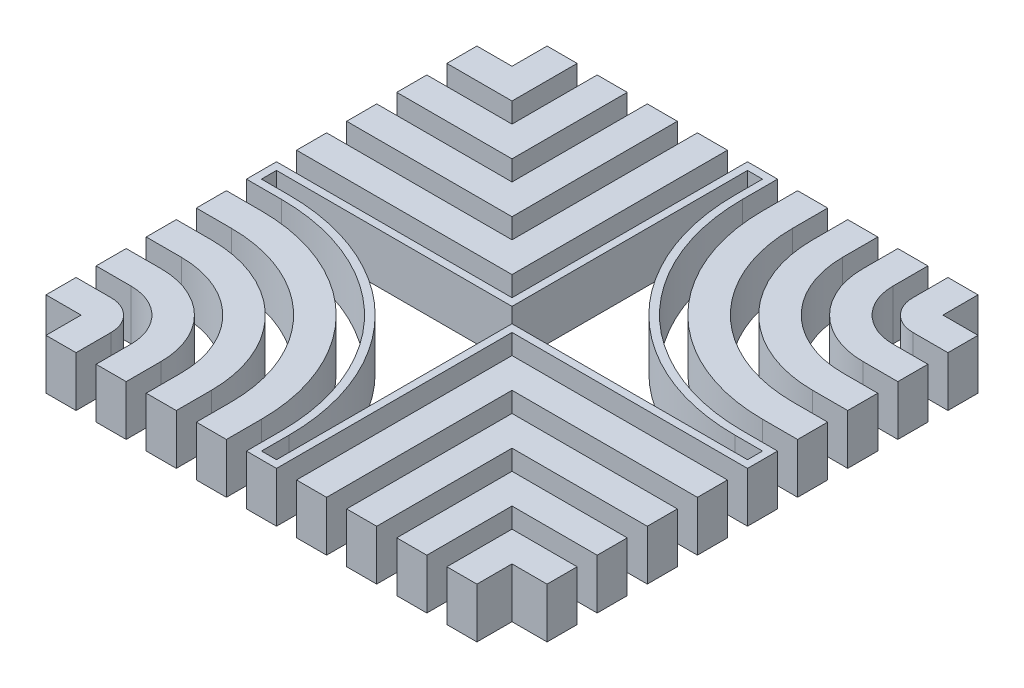
from build123d import *

# Parameters (mm, degrees)
BOSS_EXTRUDE1_DEPTH    = 10
BOSS_EXTRUDE1_2_DEPTH  = 10
BOSS_EXTRUDE1_3_DEPTH  = 10
BOSS_EXTRUDE1_4_DEPTH  = 10
BOSS_EXTRUDE1_5_DEPTH  = 10
BOSS_EXTRUDE1_6_DEPTH  = 10
BOSS_EXTRUDE1_7_DEPTH  = 10
BOSS_EXTRUDE1_8_DEPTH  = 10
BOSS_EXTRUDE1_9_DEPTH  = 10
BOSS_EXTRUDE1_10_DEPTH = 10
BOSS_EXTRUDE1_11_DEPTH = 10
BOSS_EXTRUDE1_12_DEPTH = 10
BOSS_EXTRUDE1_13_DEPTH = 10
BOSS_EXTRUDE1_14_DEPTH = 10
BOSS_EXTRUDE1_15_DEPTH = 10
BOSS_EXTRUDE1_16_DEPTH = 10
BOSS_EXTRUDE1_17_DEPTH = 10
SHELL1_T               = -1.5


with BuildPart() as part:
    # Sketch1 → Boss-Extrude1 (new body)
    with BuildSketch(Plane(origin=(0, 0, 0), x_dir=(1, 0, 0), z_dir=(0, 1, 0))):
        Polygon((-50, 37), (-37, 37), (-37, 50), (-43, 50), (-43, 43), (-50, 43), align=None)
    extrude(amount=BOSS_EXTRUDE1_DEPTH)


with BuildPart() as body_2:
    # Sketch1 → Boss-Extrude1 2 (new body)
    with BuildSketch(Plane(origin=(0, 0, 0), x_dir=(1, 0, 0), z_dir=(0, 1, 0))):
        Polygon((-50, 27), (-27, 27), (-27, 50), (-33, 50), (-33, 33), (-50, 33), align=None)
    extrude(amount=BOSS_EXTRUDE1_2_DEPTH)


with BuildPart() as body_3:
    # Sketch1 → Boss-Extrude1 3 (new body)
    with BuildSketch(Plane(origin=(0, 0, 0), x_dir=(1, 0, 0), z_dir=(0, 1, 0))):
        Polygon((-50, 17), (-17, 17), (-17, 50), (-23, 50), (-23, 23), (-50, 23), align=None)
    extrude(amount=BOSS_EXTRUDE1_3_DEPTH)


with BuildPart() as body_4:
    # Sketch1 → Boss-Extrude1 4 (new body)
    with BuildSketch(Plane(origin=(0, 0, 0), x_dir=(1, 0, 0), z_dir=(0, 1, 0))):
        Polygon((-50, 7), (-7, 7), (-7, 50), (-13, 50), (-13, 13), (-50, 13), align=None)
    extrude(amount=BOSS_EXTRUDE1_4_DEPTH)


with BuildPart() as body_5:
    # Sketch1 → Boss-Extrude1 5 (new body)
    with BuildSketch(Plane(origin=(0, 0, 0), x_dir=(1, 0, 0), z_dir=(0, 1, 0))):
        with BuildLine():
            Line((-50, -3), (-43, -3))
            ThreePointArc((-43, -3), (-14.715728753, -14.715728753), (-3, -43))
            Line((-3, -43), (-3, -50))
            Line((-3, -50), (3, -50))
            Line((3, -50), (3, -3))
            Line((3, -3), (50, -3))
            Line((50, -3), (50, 3))
            Line((50, 3), (43, 3))
            ThreePointArc((43, 3), (14.715728753, 14.715728753), (3, 43))
            Line((3, 43), (3, 50))
            Line((3, 50), (-3, 50))
            Line((-3, 50), (-3, 3))
            Line((-3, 3), (-50, 3))
            Line((-50, 3), (-50, -3))
        make_face()
    extrude(amount=BOSS_EXTRUDE1_5_DEPTH)

    # Shell1
    shell1_openings = [body_5.faces().sort_by_distance(p)[0] for p in [
        (0, 10, 0),
        (0, 0, 0),
    ]]
    offset(amount=SHELL1_T, openings=shell1_openings, kind=Kind.INTERSECTION)


with BuildPart() as body_6:
    # Sketch1 → Boss-Extrude1 6 (new body)
    with BuildSketch(Plane(origin=(0, 0, 0), x_dir=(1, 0, 0), z_dir=(0, 1, 0))):
        with BuildLine():
            Line((-50, -13), (-43, -13))
            ThreePointArc((-43, -13), (-21.786796564, -21.786796564), (-13, -43))
            Line((-13, -43), (-13, -50))
            Line((-13, -50), (-7, -50))
            Line((-7, -50), (-7, -43))
            ThreePointArc((-7, -43), (-17.544155877, -17.544155877), (-43, -7))
            Line((-43, -7), (-50, -7))
            Line((-50, -7), (-50, -13))
        make_face()
    extrude(amount=BOSS_EXTRUDE1_6_DEPTH)


with BuildPart() as body_7:
    # Sketch1 → Boss-Extrude1 7 (new body)
    with BuildSketch(Plane(origin=(0, 0, 0), x_dir=(1, 0, 0), z_dir=(0, 1, 0))):
        with BuildLine():
            Line((-50, -23), (-43, -23))
            ThreePointArc((-43, -23), (-28.857864376, -28.857864376), (-23, -43))
            Line((-23, -43), (-23, -50))
            Line((-23, -50), (-17, -50))
            Line((-17, -50), (-17, -43))
            ThreePointArc((-17, -43), (-24.615223689, -24.615223689), (-43, -17))
            Line((-43, -17), (-50, -17))
            Line((-50, -17), (-50, -23))
        make_face()
    extrude(amount=BOSS_EXTRUDE1_7_DEPTH)


with BuildPart() as body_8:
    # Sketch1 → Boss-Extrude1 8 (new body)
    with BuildSketch(Plane(origin=(0, 0, 0), x_dir=(1, 0, 0), z_dir=(0, 1, 0))):
        with BuildLine():
            Line((-50, -33), (-43, -33))
            ThreePointArc((-43, -33), (-35.928932188, -35.928932188), (-33, -43))
            Line((-33, -43), (-33, -50))
            Line((-33, -50), (-27, -50))
            Line((-27, -50), (-27, -43))
            ThreePointArc((-27, -43), (-31.686291501, -31.686291501), (-43, -27))
            Line((-43, -27), (-50, -27))
            Line((-50, -27), (-50, -33))
        make_face()
    extrude(amount=BOSS_EXTRUDE1_8_DEPTH)


with BuildPart() as body_9:
    # Sketch1 → Boss-Extrude1 9 (new body)
    with BuildSketch(Plane(origin=(0, 0, 0), x_dir=(1, 0, 0), z_dir=(0, 1, 0))):
        with BuildLine():
            Line((-50, -43), (-43, -43))
            Line((-43, -43), (-43, -50))
            Line((-43, -50), (-37, -50))
            Line((-37, -50), (-37, -43))
            ThreePointArc((-37, -43), (-38.757359313, -38.757359313), (-43, -37))
            Line((-43, -37), (-50, -37))
            Line((-50, -37), (-50, -43))
        make_face()
    extrude(amount=BOSS_EXTRUDE1_9_DEPTH)


with BuildPart() as body_10:
    # Sketch1 → Boss-Extrude1 10 (new body)
    with BuildSketch(Plane(origin=(0, 0, 0), x_dir=(1, 0, 0), z_dir=(0, 1, 0))):
        Polygon((7, -7), (50, -7), (50, -13), (13, -13), (13, -50), (7, -50), align=None)
    extrude(amount=BOSS_EXTRUDE1_10_DEPTH)


with BuildPart() as body_11:
    # Sketch1 → Boss-Extrude1 11 (new body)
    with BuildSketch(Plane(origin=(0, 0, 0), x_dir=(1, 0, 0), z_dir=(0, 1, 0))):
        Polygon((17, -17), (50, -17), (50, -23), (23, -23), (23, -50), (17, -50), align=None)
    extrude(amount=BOSS_EXTRUDE1_11_DEPTH)


with BuildPart() as body_12:
    # Sketch1 → Boss-Extrude1 12 (new body)
    with BuildSketch(Plane(origin=(0, 0, 0), x_dir=(1, 0, 0), z_dir=(0, 1, 0))):
        Polygon((27, -27), (50, -27), (50, -33), (33, -33), (33, -50), (27, -50), align=None)
    extrude(amount=BOSS_EXTRUDE1_12_DEPTH)


with BuildPart() as body_13:
    # Sketch1 → Boss-Extrude1 13 (new body)
    with BuildSketch(Plane(origin=(0, 0, 0), x_dir=(1, 0, 0), z_dir=(0, 1, 0))):
        Polygon((37, -37), (50, -37), (50, -43), (43, -43), (43, -50), (37, -50), align=None)
    extrude(amount=BOSS_EXTRUDE1_13_DEPTH)


with BuildPart() as body_14:
    # Sketch1 → Boss-Extrude1 14 (new body)
    with BuildSketch(Plane(origin=(0, 0, 0), x_dir=(1, 0, 0), z_dir=(0, 1, 0))):
        with BuildLine():
            Line((7, 50), (7, 43))
            ThreePointArc((7, 43), (17.544155877, 17.544155877), (43, 7))
            Line((43, 7), (50, 7))
            Line((50, 7), (50, 13))
            Line((50, 13), (43, 13))
            ThreePointArc((43, 13), (21.786796564, 21.786796564), (13, 43))
            Line((13, 43), (13, 50))
            Line((13, 50), (7, 50))
        make_face()
    extrude(amount=BOSS_EXTRUDE1_14_DEPTH)


with BuildPart() as body_15:
    # Sketch1 → Boss-Extrude1 15 (new body)
    with BuildSketch(Plane(origin=(0, 0, 0), x_dir=(1, 0, 0), z_dir=(0, 1, 0))):
        with BuildLine():
            Line((17, 50), (17, 43))
            ThreePointArc((17, 43), (24.615223689, 24.615223689), (43, 17))
            Line((43, 17), (50, 17))
            Line((50, 17), (50, 23))
            Line((50, 23), (43, 23))
            ThreePointArc((43, 23), (28.857864376, 28.857864376), (23, 43))
            Line((23, 43), (23, 50))
            Line((23, 50), (17, 50))
        make_face()
    extrude(amount=BOSS_EXTRUDE1_15_DEPTH)


with BuildPart() as body_16:
    # Sketch1 → Boss-Extrude1 16 (new body)
    with BuildSketch(Plane(origin=(0, 0, 0), x_dir=(1, 0, 0), z_dir=(0, 1, 0))):
        with BuildLine():
            Line((27, 50), (27, 43))
            ThreePointArc((27, 43), (31.686291501, 31.686291501), (43, 27))
            Line((43, 27), (50, 27))
            Line((50, 27), (50, 33))
            Line((50, 33), (43, 33))
            ThreePointArc((43, 33), (35.928932188, 35.928932188), (33, 43))
            Line((33, 43), (33, 50))
            Line((33, 50), (27, 50))
        make_face()
    extrude(amount=BOSS_EXTRUDE1_16_DEPTH)


with BuildPart() as body_17:
    # Sketch1 → Boss-Extrude1 17 (new body)
    with BuildSketch(Plane(origin=(0, 0, 0), x_dir=(1, 0, 0), z_dir=(0, 1, 0))):
        with BuildLine():
            Line((37, 50), (37, 43))
            ThreePointArc((37, 43), (38.757359313, 38.757359313), (43, 37))
            Line((43, 37), (50, 37))
            Line((50, 37), (50, 43))
            Line((50, 43), (43, 43))
            Line((43, 43), (43, 50))
            Line((43, 50), (37, 50))
        make_face()
    extrude(amount=BOSS_EXTRUDE1_17_DEPTH)


solid = Compound([part.part, body_2.part, body_3.part, body_4.part, body_5.part, body_6.part, body_7.part, body_8.part, body_9.part, body_10.part, body_11.part, body_12.part, body_13.part, body_14.part, body_15.part, body_16.part, body_17.part])
